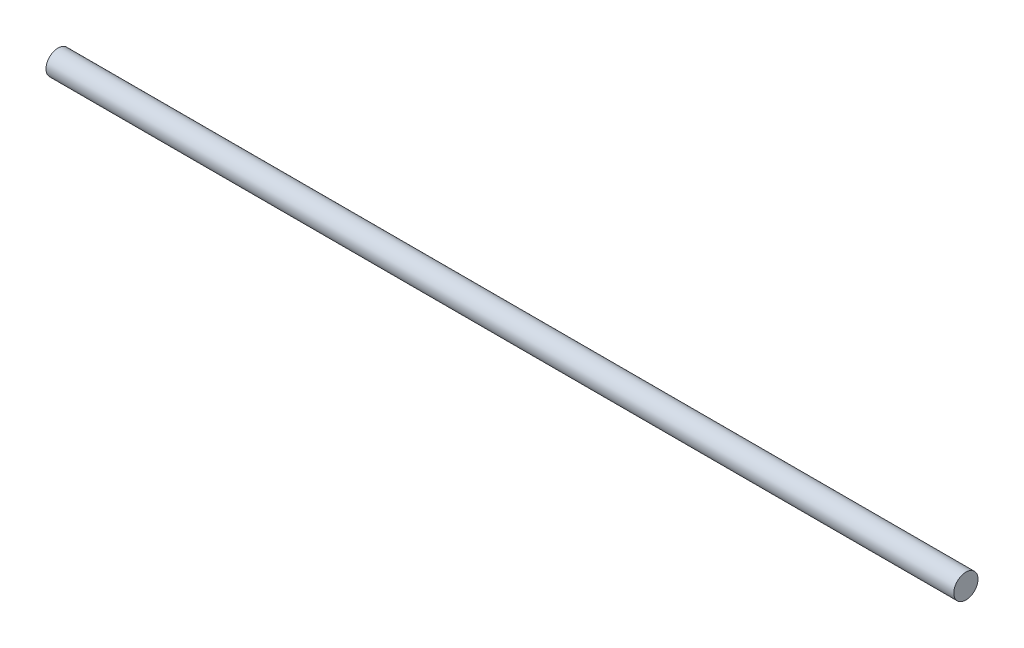
from build123d import *

# Parameters (mm, degrees)
SKETCH1_R           = 8
BOSS_EXTRUDE1_DEPTH = 600


with BuildPart() as part:
    # Sketch1 → Boss-Extrude1 (new body)
    with BuildSketch(Plane(origin=(0, 0, 0), x_dir=(0, 0, -1), z_dir=(1, 0, 0))):
        Circle(SKETCH1_R)
    extrude(amount=BOSS_EXTRUDE1_DEPTH)


solid = part.part
